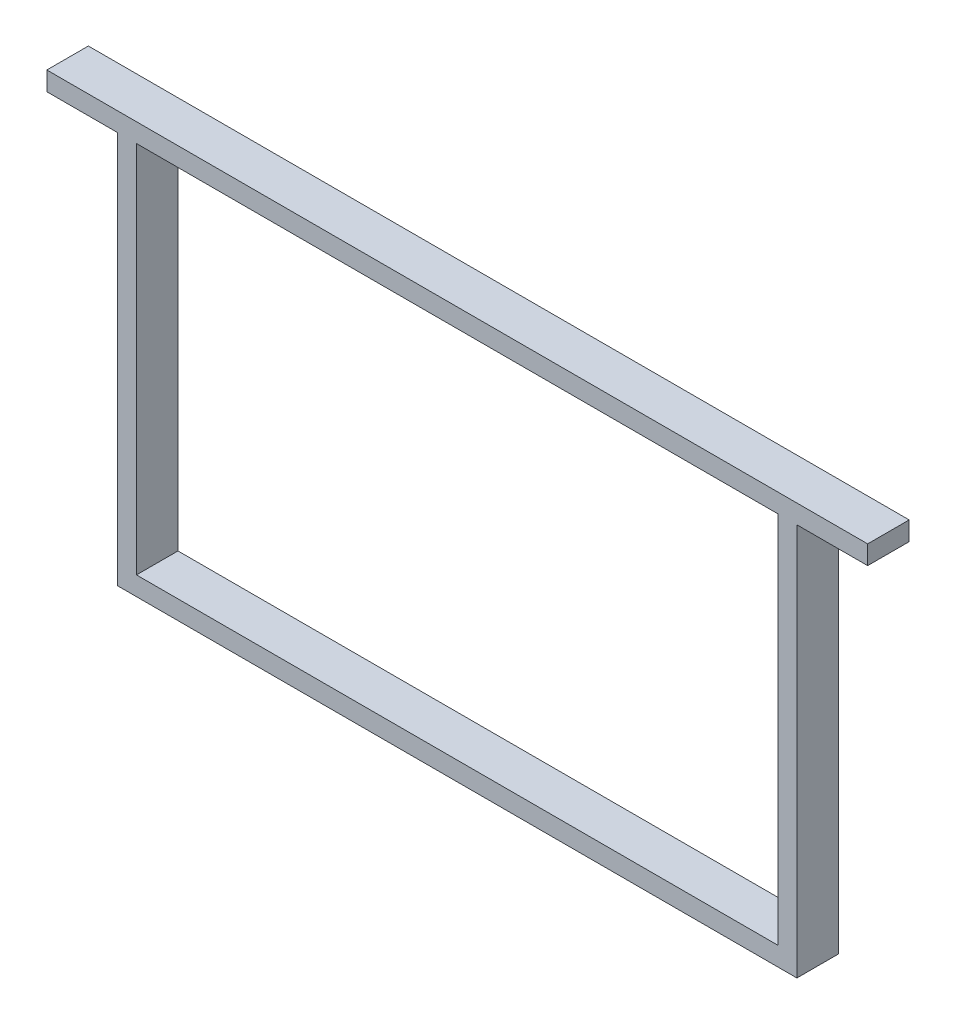
from build123d import *

# Parameters (mm, degrees)
SKETCH1_W           = 340
SKETCH1_H           = 198
BOSS_EXTRUDE1_DEPTH = 22


with BuildPart() as part:
    # Sketch1 → Boss-Extrude1 (new body)
    with BuildSketch(Plane.XY):
        Polygon((-217.5, 109), (217.5, 109), (217.5, 99), (180, 99), (180, -109), (-180, -109), (-180, 99), (-217.5, 99), align=None)
        Rectangle(SKETCH1_W, SKETCH1_H, mode=Mode.SUBTRACT)
    extrude(amount=BOSS_EXTRUDE1_DEPTH)


solid = part.part
